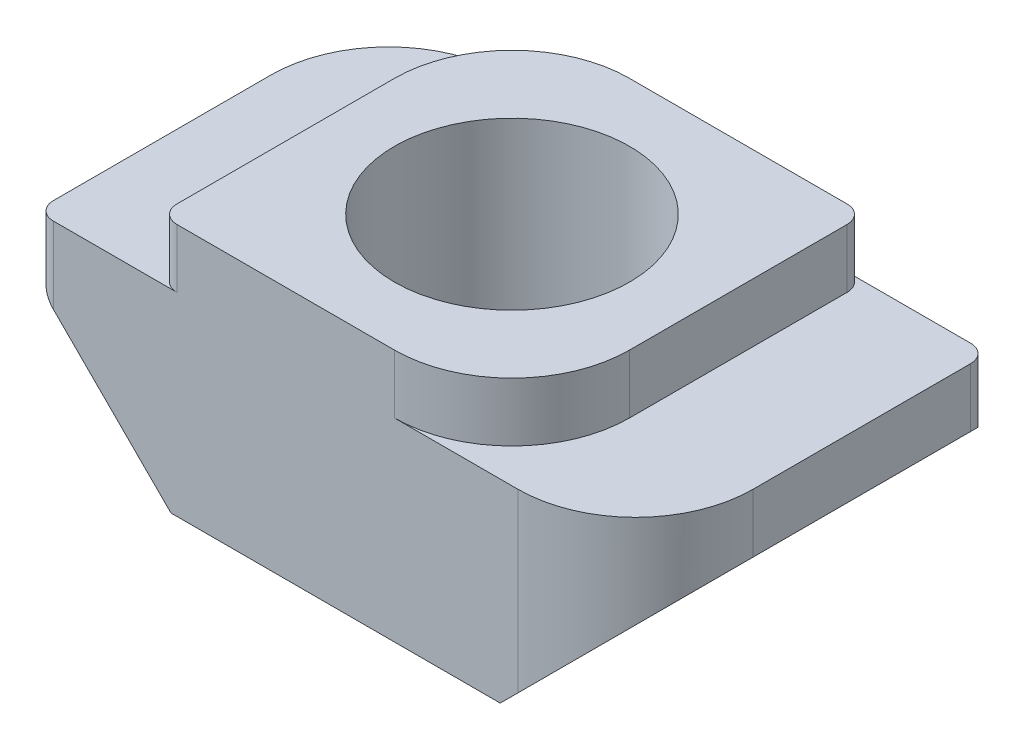
from build123d import *

# Parameters (mm, degrees)
EXTRUDE_1_DEPTH     = 6
FILLET_1_R          = 2
FILLET_2_R          = 2
FILLET_3_R          = 0.3
SKETCH_2_R          = 2
CUT_EXTRUDE_1_DEPTH = 6


with BuildPart() as part:
    # 草图1 → 凸台-拉伸1 (new body)
    with BuildSketch(Plane.XY):
        Polygon((-3, 4.3), (3, 4.3), (3, 3.3), (5.1, 3.3), (5.1, 2.3), (2.8, 0), (-2.8, 0), (-5.1, 2.3), (-5.1, 3.3), (-3, 3.3), align=None)
    extrude(amount=EXTRUDE_1_DEPTH)

    # 圆角1
    fillet_1_edges = [part.edges().sort_by_distance(p)[0] for p in [
        (-3, 3.8, 0),
        (3, 3.8, 6),
    ]]
    fillet(fillet_1_edges, radius=FILLET_1_R)

    # 圆角2
    fillet_2_edges = [part.edges().sort_by_distance(p)[0] for p in [
        (-5.1, 2.8, 0),
        (5.1, 2.8, 6),
    ]]
    fillet(fillet_2_edges, radius=FILLET_2_R)

    # 圆角3
    fillet_3_edges = [part.edges().sort_by_distance(p)[0] for p in [
        (-3, 3.8, 6),
        (3, 3.8, 0),
        (-5.1, 2.8, 6),
        (5.1, 2.8, 0),
    ]]
    fillet(fillet_3_edges, radius=FILLET_3_R)

    # 草图2 → 切除-拉伸1 (cut)
    with BuildSketch(Plane(origin=(0, 4.3, 0), x_dir=(1, 0, 0), z_dir=(0, 1, 0))):
        with Locations((0, -3)):
            Circle(SKETCH_2_R)
    extrude(amount=-CUT_EXTRUDE_1_DEPTH, mode=Mode.SUBTRACT)


solid = part.part
